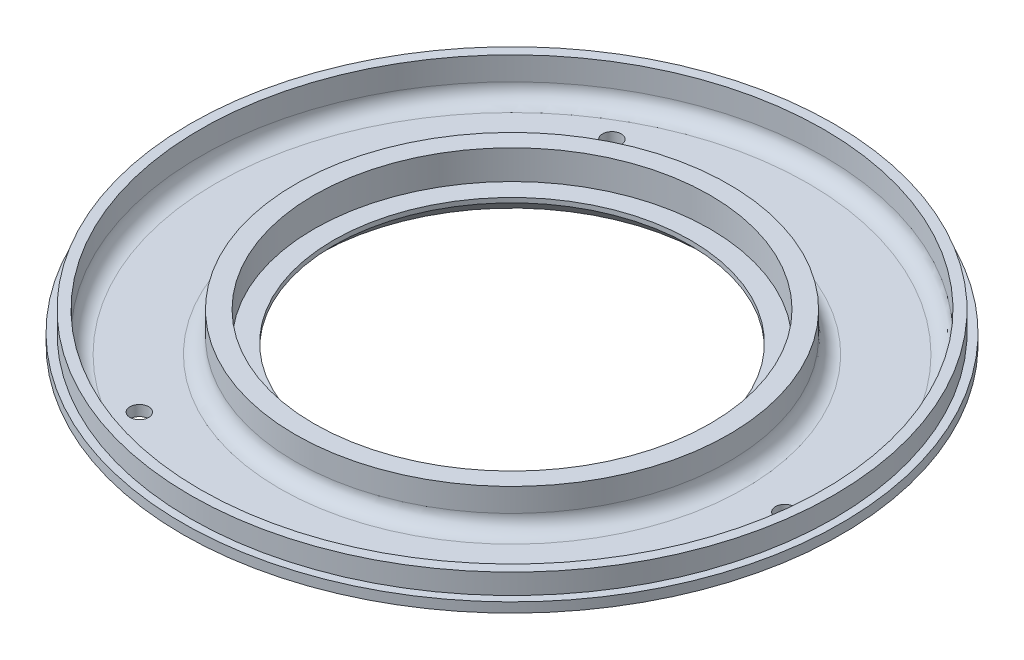
from build123d import *

# Parameters (mm, degrees)
F_90_0_0087_DIAMETER_HOLE1_D = 0.22098
CIRPATTERN3_COUNT            = 3
SKETCH8_R                    = 80.01
SKETCH8_R_2                  = 55.626
CUT_EXTRUDE1_DEPTH           = 10
FILLET5_R                    = 4
CHAMFER1_SIZE                = 4
SKETCH10_R                   = 84.55
SKETCH10_R_2                 = 82.55
BOSS_EXTRUDE1_DEPTH          = 7.5
CHAMFER3_SIZE                = 5
CHAMFER3_SIZE2               = 8.660254038
FILLET4_R                    = 5
F_12_0_189_DIAMETER_HOLE1_D  = 4.8006
CIRPATTERN5_COUNT            = 3


with BuildPart() as part:
    # Sketch2 → Revolve1 (revolve)
    with BuildSketch(Plane(origin=(0, 0, 0), x_dir=(0, 0, -1), z_dir=(1, 0, 0))):
        Polygon((-45.8, 0), (-82.55, 0), (-82.55, 12.7), (-50.8, 12.7), (-50.8, 5.2), (-45.8, 5.2), align=None)
    revolve(axis=Axis((0, -0.635, 0), (0, 1, 0)))

    # #90 (0.0087) Diameter Hole1 (through all)
    with Locations(Plane(origin=(0, 12.7, 0), x_dir=(1, 0, 0), z_dir=(0, 1, 0))):
        with Locations((-35, 60.621778265)):
            f_90_0_0087_diameter_hole1 = Hole(F_90_0_0087_DIAMETER_HOLE1_D / 2)

    # CirPattern3: #90 (0.0087) Diameter Hole1 ×3 about axis
    cirpattern3_axis = Axis((0, 0, 0), (0, 1, 0))
    for i in range(1, CIRPATTERN3_COUNT):
        add(f_90_0_0087_diameter_hole1.rotate(cirpattern3_axis, i * 360 / CIRPATTERN3_COUNT), mode=Mode.SUBTRACT)

    # Sketch8 → Cut-Extrude1 (cut)
    with BuildSketch(Plane(origin=(0, 12.7, 0), x_dir=(1, 0, 0), z_dir=(0, 1, 0))):
        Circle(SKETCH8_R)
        Circle(SKETCH8_R_2, mode=Mode.SUBTRACT)
    extrude(amount=-CUT_EXTRUDE1_DEPTH, mode=Mode.SUBTRACT)

    # Fillet5
    fillet5_edges = [part.edges().sort_by_distance(p)[0] for p in [
        (-55.626, 2.7, 0),
        (-80.01, 2.7, 0),
    ]]
    fillet(fillet5_edges, radius=FILLET5_R)

    # Chamfer1
    chamfer1_edges = [part.edges().sort_by_distance(p)[0] for p in [
        (0, 0, -45.8),
    ]]
    chamfer(chamfer1_edges, length=CHAMFER1_SIZE)

    # Sketch10 → Boss-Extrude1 (add)
    with BuildSketch(Plane.XZ):
        Circle(SKETCH10_R)
        Circle(SKETCH10_R_2, mode=Mode.SUBTRACT)
    extrude(amount=-BOSS_EXTRUDE1_DEPTH)

    # Chamfer3
    chamfer3_edges = [part.edges().sort_by_distance(p)[0] for p in [
        (-84.55, 0, 0),
    ]]
    chamfer3_side = [part.faces().sort_by_distance(p)[0] for p in [
        (-84.55, 3.75, 0),
    ]]
    chamfer(chamfer3_edges, length=CHAMFER3_SIZE, length2=CHAMFER3_SIZE2, reference=chamfer3_side[0])

    # Fillet4
    fillet4_edges = [part.edges().sort_by_distance(p)[0] for p in [
        (-75.889745962, 0, 0),
    ]]
    fillet(fillet4_edges, radius=FILLET4_R)

    # #12 (0.189) Diameter Hole1 (through all)
    with Locations(Plane(origin=(0, 0, 0), x_dir=(-1, 0, 0), z_dir=(0, -1, 0))):
        with Locations((35, 60.621778265)):
            f_12_0_189_diameter_hole1 = Hole(F_12_0_189_DIAMETER_HOLE1_D / 2)

    # CirPattern5: #12 (0.189) Diameter Hole1 ×3 about axis
    cirpattern5_axis = Axis((0, 0, 0), (0, 1, 0))
    for i in range(1, CIRPATTERN5_COUNT):
        add(f_12_0_189_diameter_hole1.rotate(cirpattern5_axis, i * 360 / CIRPATTERN5_COUNT), mode=Mode.SUBTRACT)


solid = part.part
